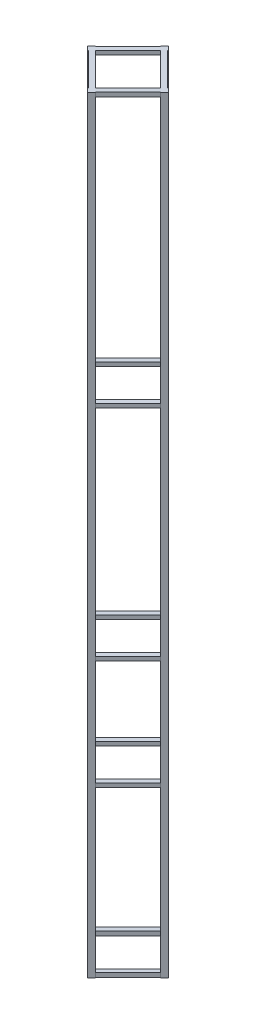
from build123d import *

# Parameters (mm, degrees)
BOSS_EXTRUDE6_DEPTH   = 1778
BOSS_EXTRUDE6_2_DEPTH = 1778
BOSS_EXTRUDE6_3_DEPTH = 1778
BOSS_EXTRUDE6_4_DEPTH = 1778
SKETCH11_W            = 11.1125
SKETCH11_H            = 9.525
BOSS_EXTRUDE11_DEPTH  = 129.12986
SKETCH13_W            = 11.1125
SKETCH13_H            = 9.525
BOSS_EXTRUDE13_DEPTH  = 118.01736
SKETCH14_W            = 11.1125
SKETCH14_H            = 9.525
BOSS_EXTRUDE14_DEPTH  = 119.60486
SKETCH15_W            = 11.1125
SKETCH15_H            = 9.525
BOSS_EXTRUDE15_DEPTH  = 106.90486
LPATTERN1_COUNT       = 2
LPATTERN1_PITCH       = 381
LPATTERN2_COUNT       = 2
LPATTERN2_PITCH       = 635
LPATTERN3_COUNT       = 2
LPATTERN3_PITCH       = 1143
LPATTERN4_COUNT       = 2
LPATTERN4_PITCH       = 1768.475


with BuildPart() as part:
    # Sketch2 → Boss-Extrude6 (new body)
    with BuildSketch(Plane(origin=(0, 0, 0), x_dir=(1, 0, 0), z_dir=(0, 1, 0))):
        Polygon((0, 93.553663338), (-8.980256121, 84.573407217), (-7.857724106, 83.450875201), (0, 91.308599307), (7.857724106, 83.450875201), (8.980256121, 84.573407217), align=None)
    extrude(amount=BOSS_EXTRUDE6_DEPTH)



with BuildPart() as body_2:
    # Sketch2 → Boss-Extrude6 2 (new body)
    with BuildSketch(Plane(origin=(0, 0, 0), x_dir=(1, 0, 0), z_dir=(0, 1, 0))):
        Polygon((93.553663338, 0), (84.573407217, 8.980256121), (83.450875201, 7.857724106), (91.308599307, 0), (83.450875201, -7.857724106), (84.573407217, -8.980256121), align=None)
    extrude(amount=BOSS_EXTRUDE6_2_DEPTH)



with BuildPart() as body_3:
    # Sketch2 → Boss-Extrude6 3 (new body)
    with BuildSketch(Plane(origin=(0, 0, 0), x_dir=(1, 0, 0), z_dir=(0, 1, 0))):
        Polygon((0, -93.553663338), (8.980256121, -84.573407217), (7.857724106, -83.450875201), (0, -91.308599307), (-7.857724106, -83.450875201), (-8.980256121, -84.573407217), align=None)
    extrude(amount=BOSS_EXTRUDE6_3_DEPTH)



with BuildPart() as body_4:
    # Sketch2 → Boss-Extrude6 4 (new body)
    with BuildSketch(Plane(origin=(0, 0, 0), x_dir=(1, 0, 0), z_dir=(0, 1, 0))):
        Polygon((-93.553663338, 0), (-84.573407217, -8.980256121), (-83.450875201, -7.857724106), (-91.308599307, 0), (-83.450875201, 7.857724106), (-84.573407217, 8.980256121), align=None)
    extrude(amount=BOSS_EXTRUDE6_4_DEPTH)


with BuildPart() as body_3_1:
    add(body_3.part)

    add(body_4.part)  # Boss-Extrude11 merges body 4
    # Sketch11 → Boss-Extrude11 (add)
    with BuildSketch(Plane(origin=(-45.654299654, 0, -45.654299654), x_dir=(0.707106781, 0, -0.707106781), z_dir=(0.707106781, 0, 0.707106781))):
        with Locations((-59.008679751, 4.7625)):
            Rectangle(SKETCH11_W, SKETCH11_H)
    boss_extrude11 = extrude(amount=BOSS_EXTRUDE11_DEPTH)


with BuildPart() as body_2_1:
    add(body_2.part)

    add(body_3_1.part)  # Boss-Extrude13 merges body 3
    # Sketch13 → Boss-Extrude13 (add)
    with BuildSketch(Plane(origin=(-37.796575548, 0, 37.796575548), x_dir=(-0.707106781, 0, -0.707106781), z_dir=(0.707106781, 0, -0.707106781))):
        with Locations((-59.008679751, 4.7625)):
            Rectangle(SKETCH13_W, SKETCH13_H)
    boss_extrude13 = extrude(amount=BOSS_EXTRUDE13_DEPTH)


with BuildPart() as part_1:
    add(part.part)

    add(body_2_1.part)  # Boss-Extrude14 merges body 2
    # Sketch14 → Boss-Extrude14 (add)
    with BuildSketch(Plane(origin=(37.796575548, 0, 37.796575548), x_dir=(-0.707106781, 0, 0.707106781), z_dir=(-0.707106781, 0, -0.707106781))):
        with Locations((-59.008679751, 4.7625)):
            Rectangle(SKETCH14_W, SKETCH14_H)
    boss_extrude14 = extrude(amount=BOSS_EXTRUDE14_DEPTH)

    # Sketch15 → Boss-Extrude15 (add)
    with BuildSketch(Plane(origin=(37.796575548, 0, -37.796575548), x_dir=(0.707106781, 0, 0.707106781), z_dir=(-0.707106781, 0, 0.707106781))):
        with Locations((-59.008679751, 4.7625)):
            Rectangle(SKETCH15_W, SKETCH15_H)
    boss_extrude15 = extrude(amount=BOSS_EXTRUDE15_DEPTH)

    # LPattern1: Boss-Extrude11, Boss-Extrude13, Boss-Extrude14, Boss-Extrude15 ×2
    with Locations(*[(0, i * LPATTERN1_PITCH, 0) for i in range(1, LPATTERN1_COUNT)]):
        add(boss_extrude11)
        add(boss_extrude13)
        add(boss_extrude14)
        add(boss_extrude15)

    # LPattern2: Boss-Extrude11, Boss-Extrude13, Boss-Extrude14, Boss-Extrude15 ×2
    with Locations(*[(0, i * LPATTERN2_PITCH, 0) for i in range(1, LPATTERN2_COUNT)]):
        add(boss_extrude11)
        add(boss_extrude13)
        add(boss_extrude14)
        add(boss_extrude15)

    # LPattern3: Boss-Extrude11, Boss-Extrude13, Boss-Extrude14, Boss-Extrude15 ×2
    with Locations(*[(0, i * LPATTERN3_PITCH, 0) for i in range(1, LPATTERN3_COUNT)]):
        add(boss_extrude11)
        add(boss_extrude13)
        add(boss_extrude14)
        add(boss_extrude15)

    # LPattern4: Boss-Extrude11, Boss-Extrude13, Boss-Extrude14, Boss-Extrude15 ×2
    with Locations(*[(0, i * LPATTERN4_PITCH, 0) for i in range(1, LPATTERN4_COUNT)]):
        add(boss_extrude11)
        add(boss_extrude13)
        add(boss_extrude14)
        add(boss_extrude15)


solid = part_1.part
